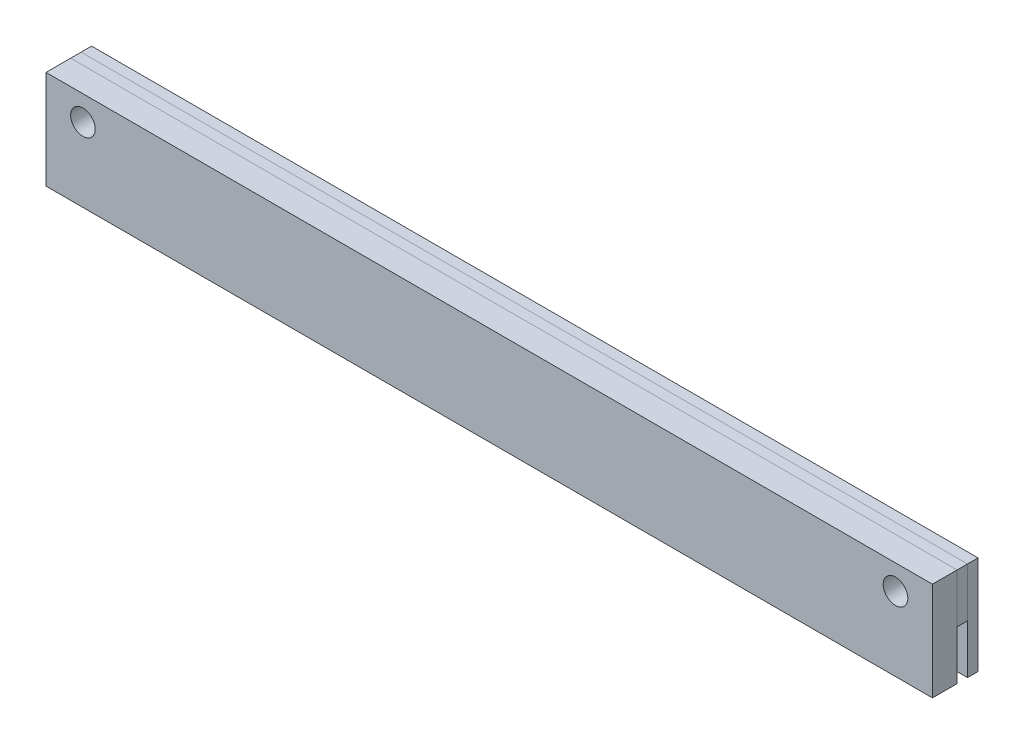
from build123d import *

# Parameters (mm, degrees)
SKETCH2_W           = 6.35
SKETCH2_H           = 25.4
BOSS_EXTRUDE1_DEPTH = 114.3
SKETCH2_4_W         = 2.7
SKETCH2_4_H         = 12.7
BOSS_EXTRUDE2_DEPTH = 114.3
BOSS_EXTRUDE3_DEPTH = 114.3
SKETCH4_R           = 3.175
CUT_EXTRUDE4_DEPTH  = 11.75


with BuildPart() as part:
    # Sketch2 → Boss-Extrude1 (new body, symmetric)
    with BuildSketch(Plane(origin=(0, 0, 0), x_dir=(0, 0, -1), z_dir=(1, 0, 0))):
        with Locations((-4.525, -6.35)):
            Rectangle(SKETCH2_W, SKETCH2_H)
    extrude(amount=BOSS_EXTRUDE1_DEPTH, both=True)


with BuildPart() as body_2:
    # Sketch2_4 → Boss-Extrude2 (new body, symmetric)
    with BuildSketch(Plane(origin=(0, 0, 0), x_dir=(0, 0, -1), z_dir=(1, 0, 0))):
        Rectangle(SKETCH2_4_W, SKETCH2_4_H)
    extrude(amount=BOSS_EXTRUDE2_DEPTH, both=True)


with BuildPart() as body_3:
    # Sketch2_5 → Boss-Extrude3 (new body, symmetric)
    with BuildSketch(Plane(origin=(0, 0, 0), x_dir=(0, 0, -1), z_dir=(1, 0, 0))):
        Polygon((4.05, 6.35), (1.35, 6.35), (1.35, -6.35), (1.35, -19.05), (4.05, -19.05), align=None)
    extrude(amount=BOSS_EXTRUDE3_DEPTH, both=True)


with BuildPart() as cut_extrude4_tool:
    # Sketch4 → Cut-Extrude4 (new body)
    with BuildSketch(Plane.XY.offset(7.7)):
        with Locations((-104.775, 0)):
            Circle(SKETCH4_R)
        with Locations((104.775, 0)):
            Circle(SKETCH4_R)
    extrude(amount=-CUT_EXTRUDE4_DEPTH)


with BuildPart() as part_1:
    add(part.part)

    # Cut-Extrude4: cut by cut_extrude4_tool
    add(cut_extrude4_tool.part, mode=Mode.SUBTRACT)


with BuildPart() as body_2_1:
    add(body_2.part)

    # Cut-Extrude4: cut by cut_extrude4_tool
    add(cut_extrude4_tool.part, mode=Mode.SUBTRACT)


with BuildPart() as body_3_1:
    add(body_3.part)

    # Cut-Extrude4: cut by cut_extrude4_tool
    add(cut_extrude4_tool.part, mode=Mode.SUBTRACT)


solid = Compound([part_1.part, body_2_1.part, body_3_1.part])
